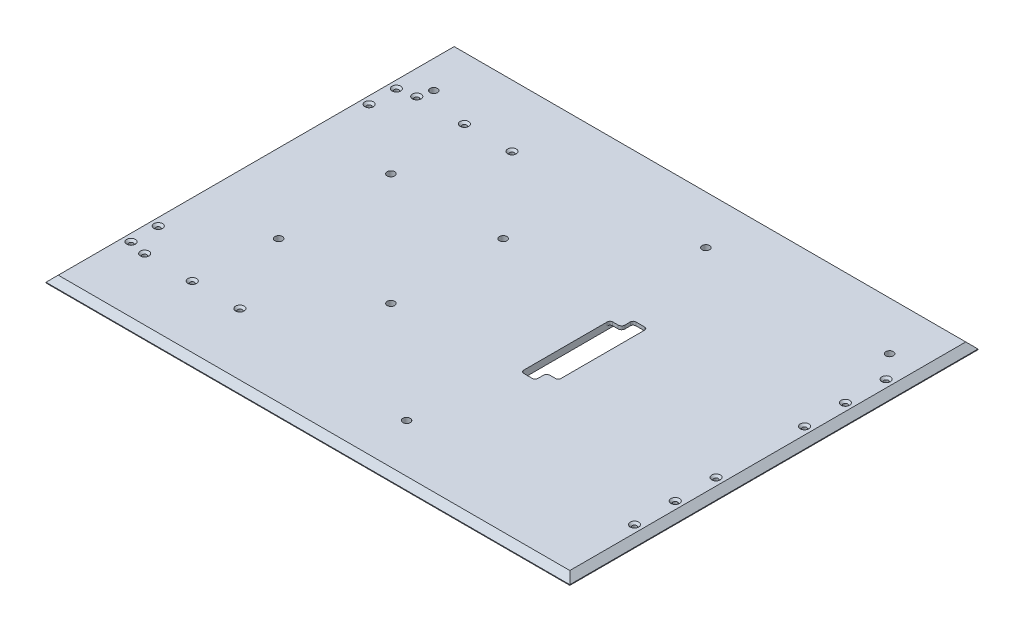
from build123d import *

# Parameters (mm, degrees)
SKETCH1_W                                           = 770
SKETCH1_H                                           = 600
BOSS_EXTRUDE1_DEPTH                                 = 10
CHAMFER1_SIZE                                       = 9
CUT_EXTRUDE1_DEPTH                                  = 11
FILLET1_R                                           = 5
FILLET2_R                                           = 4
CUT_EXTRUDE2_DEPTH                                  = 5
SKETCH4_R                                           = 10
BOSS_EXTRUDE2_DEPTH                                 = 9
MIRROR2_COPY_1_SKETCH_R                             = 10
MIRROR2_COPY_1_DEPTH                                = 9
SKETCH5_R                                           = 10
BOSS_EXTRUDE3_DEPTH                                 = 9
SKETCH6_R                                           = 5.5
CUT_EXTRUDE3_DEPTH                                  = 20
SKETCH7_R                                           = 5.5
CUT_EXTRUDE4_DEPTH                                  = 20
SKETCH8_R                                           = 5.5
BOSS_EXTRUDE5_DEPTH                                 = 15
CHAMFER2_SIZE                                       = 2.5
CHAMFER3_SIZE                                       = 2.5
CSK_FOR_M6_COUNTERSUNK_FLAT_HEAD_SCREW1_D           = 6.6
CSK_FOR_M6_COUNTERSUNK_FLAT_HEAD_SCREW1_DEPTH       = 23
CSK_FOR_M6_COUNTERSUNK_FLAT_HEAD_SCREW1_CSINK_D     = 12.6
CSK_FOR_M6_COUNTERSUNK_FLAT_HEAD_SCREW1_CSINK_ANGLE = 90
CSK_FOR_M6_COUNTERSUNK_FLAT_HEAD_SCREW1_TIP         = 1.982840043
SKETCH11_R                                          = 5.5
CUT_EXTRUDE5_DEPTH                                  = 35


with BuildPart() as part:
    # Sketch1 → Boss-Extrude1 (new body)
    with BuildSketch(Plane(origin=(0, 0, 0), x_dir=(1, 0, 0), z_dir=(0, 1, 0))):
        with Locations((385, 300)):
            Rectangle(SKETCH1_W, SKETCH1_H)
    extrude(amount=BOSS_EXTRUDE1_DEPTH)

    # Chamfer1
    chamfer1_edges = [part.edges().sort_by_distance(p)[0] for p in [
        (770, 10, -300),
        (385, 10, -600),
        (0, 10, -300),
        (385, 10, 0),
    ]]
    chamfer(chamfer1_edges, length=CHAMFER1_SIZE)

    # Sketch2 → Cut-Extrude1 (cut, through all)
    with BuildSketch(Plane(origin=(0, 10, 0), x_dir=(1, 0, 0), z_dir=(0, 1, 0))):
        Polygon((472, 226), (472, 357), (489, 357), (489, 374), (510, 374), (510, 243), (493, 243), (493, 226), align=None)
    extrude(amount=-CUT_EXTRUDE1_DEPTH, mode=Mode.SUBTRACT)

    # Fillet1
    fillet1_edges = [part.edges().sort_by_distance(p)[0] for p in [
        (489, 5, -357),
        (493, 5, -243),
    ]]
    fillet(fillet1_edges, radius=FILLET1_R)

    # Fillet2
    fillet2_edges = [part.edges().sort_by_distance(p)[0] for p in [
        (493, 5, -226),
        (472, 5, -226),
        (472, 5, -357),
        (489, 5, -374),
        (510, 5, -374),
        (510, 5, -243),
    ]]
    fillet(fillet2_edges, radius=FILLET2_R)

    # Sketch3 → Cut-Extrude2 (cut)
    with BuildSketch(Plane.XZ):
        with BuildLine():
            Line((505, -218), (477, -218))
            ThreePointArc((477, -218), (473.464466094, -219.464466094), (472, -223))
            Line((472, -223), (472, -377))
            ThreePointArc((472, -377), (473.464466094, -380.535533906), (477, -382))
            Line((477, -382), (505, -382))
            ThreePointArc((505, -382), (508.535533906, -380.535533906), (510, -377))
            Line((510, -377), (510, -223))
            ThreePointArc((510, -223), (508.535533906, -219.464466094), (505, -218))
        make_face()
    extrude(amount=-CUT_EXTRUDE2_DEPTH, mode=Mode.SUBTRACT)

    # Sketch4 → Boss-Extrude2 (add)
    with BuildSketch(Plane.XZ):
        with Locations(Location((50, -80, 0), (0, 0, 270))):  # turned: the seam where the file's is
            Circle(SKETCH4_R)
    boss_extrude2 = extrude(amount=BOSS_EXTRUDE2_DEPTH)

    # Mirror1: Boss-Extrude2 across plane
    add(boss_extrude2.mirror(Plane.ZY.offset(-385)))

    # Mirror2: Boss-Extrude2 across plane
    add(boss_extrude2.mirror(Plane.XY.offset(-300)))

    # Mirror2 copy 1 sketch → Mirror2 copy 1 (add)
    with BuildSketch(Plane(origin=(770, 0, -600), x_dir=(-1, 0, 0), z_dir=(0, -1, 0))):
        with Locations(Location((50, -80, 0), (0, 0, 270))):  # turned: the seam where the file's is
            Circle(MIRROR2_COPY_1_SKETCH_R)
    extrude(amount=MIRROR2_COPY_1_DEPTH)

    # Sketch5 → Boss-Extrude3 (add)
    with BuildSketch(Plane.XZ):
        with Locations(Location((450, -80, 0), (0, 0, 270))):  # turned: the seam where the file's is
            Circle(SKETCH5_R)
    boss_extrude3 = extrude(amount=BOSS_EXTRUDE3_DEPTH)

    # Mirror3: Boss-Extrude3 across plane
    add(boss_extrude3.mirror(Plane.XY.offset(-300)))

    # Sketch6 → Cut-Extrude3 (cut, through all)
    with BuildSketch(Plane.XZ.offset(9)):
        with Locations(Location((50, -520, 0), (0, 0, 270))):  # turned: the seam where the file's is
            Circle(SKETCH6_R)
    cut_extrude3 = extrude(amount=-CUT_EXTRUDE3_DEPTH, mode=Mode.SUBTRACT)

    # Mirror4: Cut-Extrude3 across plane
    add(cut_extrude3.mirror(Plane.ZY.offset(-385)), mode=Mode.SUBTRACT)

    # Sketch7 → Cut-Extrude4 (cut, through all)
    with BuildSketch(Plane.XZ.offset(9)):
        with Locations(Location((450, -520, 0), (0, 0, 270))):  # turned: the seam where the file's is
            Circle(SKETCH7_R)
    cut_extrude4 = extrude(amount=-CUT_EXTRUDE4_DEPTH, mode=Mode.SUBTRACT)

    # Mirror5: Cut-Extrude4 across plane
    add(cut_extrude4.mirror(Plane.XY.offset(-300)), mode=Mode.SUBTRACT)

    # Sketch8 → Boss-Extrude5 (add)
    with BuildSketch(Plane.XZ.offset(9)):
        with Locations(Location((50, -80, 0), (0, 0, 270))):  # turned: the seam where the file's is
            Circle(SKETCH8_R)
    boss_extrude5 = extrude(amount=BOSS_EXTRUDE5_DEPTH)

    # Chamfer2
    chamfer2_edges = [part.edges().sort_by_distance(p)[0] for p in [
        (50, -24, -74.5),
    ]]
    chamfer(chamfer2_edges, length=CHAMFER2_SIZE)

    # Mirror7: Boss-Extrude5 across plane
    add(boss_extrude5.mirror(Plane.ZY.offset(-385)))

    # Chamfer3
    chamfer3_edges = [part.edges().sort_by_distance(p)[0] for p in [
        (720, -24, -74.5),
    ]]
    chamfer(chamfer3_edges, length=CHAMFER3_SIZE)

    # CSK for M6 Countersunk Flat Head Screw1
    with Locations(Plane(origin=(0, 10, 0), x_dir=(1, 0, 0), z_dir=(0, 1, 0))):
        with Locations((45, 500), (115, 500), (185, 500), (20, 145), (20, 105), (45, 100), (115, 100), (185, 100), (750, 115), (750, 175), (750, 235), (750, 365), (750, 425), (750, 485), (20, 495), (20, 455)):
            CounterSinkHole(CSK_FOR_M6_COUNTERSUNK_FLAT_HEAD_SCREW1_D / 2, CSK_FOR_M6_COUNTERSUNK_FLAT_HEAD_SCREW1_CSINK_D / 2, depth=CSK_FOR_M6_COUNTERSUNK_FLAT_HEAD_SCREW1_DEPTH, counter_sink_angle=CSK_FOR_M6_COUNTERSUNK_FLAT_HEAD_SCREW1_CSINK_ANGLE)
            with Locations((0, 0, -(CSK_FOR_M6_COUNTERSUNK_FLAT_HEAD_SCREW1_DEPTH + CSK_FOR_M6_COUNTERSUNK_FLAT_HEAD_SCREW1_TIP / 2))):  # 118° drill point
                Cone(0, CSK_FOR_M6_COUNTERSUNK_FLAT_HEAD_SCREW1_D / 2, CSK_FOR_M6_COUNTERSUNK_FLAT_HEAD_SCREW1_TIP, mode=Mode.SUBTRACT)

    # Sketch11 → Cut-Extrude5 (cut, through all)
    with BuildSketch(Plane(origin=(0, 10, 0), x_dir=(1, 0, 0), z_dir=(0, 1, 0))):
        with Locations(Location((289.5, 382.5, 0), (0, 0, 270))):  # turned: the seam where the file's is
            Circle(SKETCH11_R)
        with Locations(Location((289.5, 217.5, 0), (0, 0, 270))):  # turned: the seam where the file's is
            Circle(SKETCH11_R)
        with Locations(Location((124.5, 217.5, 0), (0, 0, 270))):  # turned: the seam where the file's is
            Circle(SKETCH11_R)
        with Locations(Location((124.5, 382.5, 0), (0, 0, 270))):  # turned: the seam where the file's is
            Circle(SKETCH11_R)
    extrude(amount=-CUT_EXTRUDE5_DEPTH, mode=Mode.SUBTRACT)


solid = part.part
